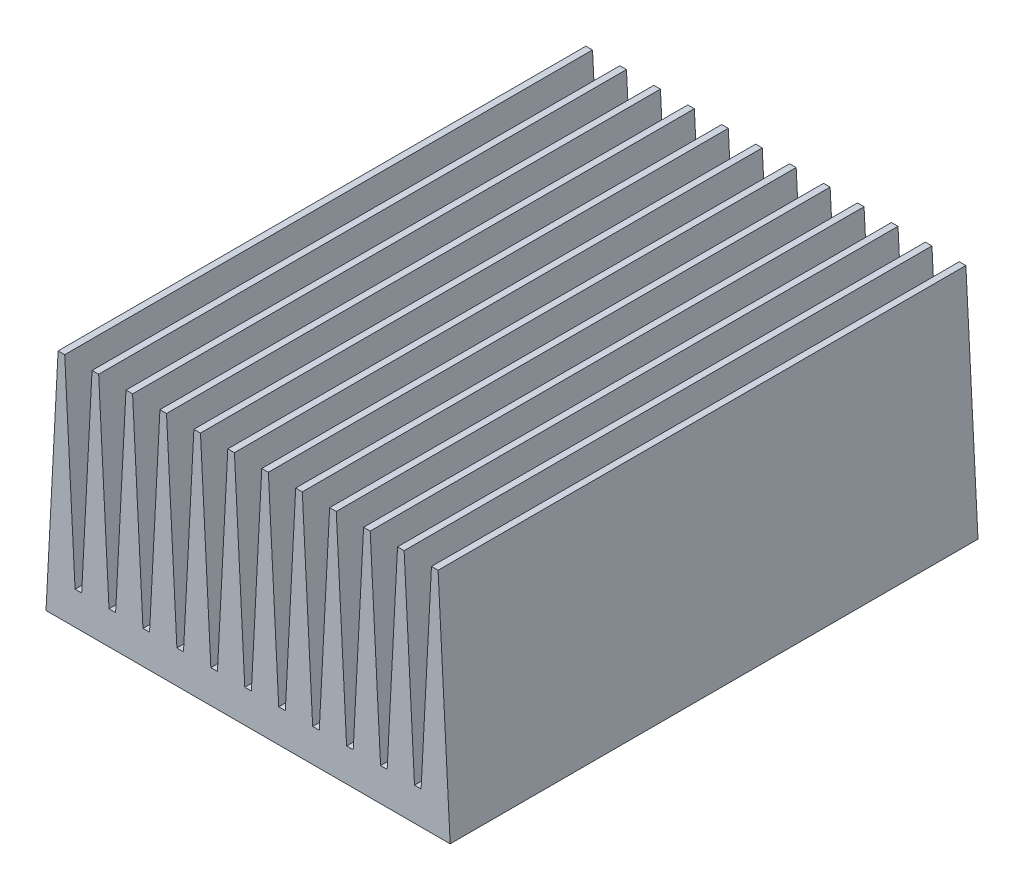
from build123d import *

# Parameters (mm, degrees)
BOSS_EXTRUDE1_DEPTH = 80


with BuildPart() as part:
    # Sketch2 → Boss-Extrude1 (new body)
    with BuildSketch(Plane.XY):
        Polygon((-20.657894737, -2.5), (20.657894737, -2.5), (20.39585584, 2.5), (18.823622462, 32.5), (17.823622462, 32.5), (16.251389083, 2.5), (15.251389083, 2.5), (13.679155705, 32.5), (12.679155705, 32.5), (11.106922326, 2.5), (10.106922326, 2.5), (8.534688948, 32.5), (7.534688948, 32.5), (5.962455569, 2.5), (4.962455569, 2.5), (3.390222191, 32.5), (2.390222191, 32.5), (0.817988812, 2.5), (-0.182011188, 2.5), (-1.754244566, 32.5), (-2.754244566, 32.5), (-4.326477944, 2.5), (-5.326477944, 2.5), (-6.898711323, 32.5), (-7.898711323, 32.5), (-9.470944701, 2.5), (-10.470944701, 2.5), (-12.04317808, 32.5), (-13.04317808, 32.5), (-14.615411458, 2.5), (-15.615411458, 2.5), (-17.187644837, 32.5), (-18.187644837, 32.5), (-19.759878215, 2.5), (-20.759878215, 2.5), (-22.332111594, 32.5), (-23.332111594, 32.5), (-24.904344972, 2.5), (-25.904344972, 2.5), (-27.476578351, 32.5), (-28.476578351, 32.5), (-30.048811729, 2.5), (-31.048811729, 2.5), (-32.621045108, 32.5), (-33.621045108, 32.5), (-35.193278486, 2.5), (-36.193278486, 2.5), (-37.765511865, 32.5), (-38.765511865, 32.5), (-40.337745243, 2.5), (-40.59978414, -2.5), align=None)
    extrude(amount=BOSS_EXTRUDE1_DEPTH)


solid = part.part
